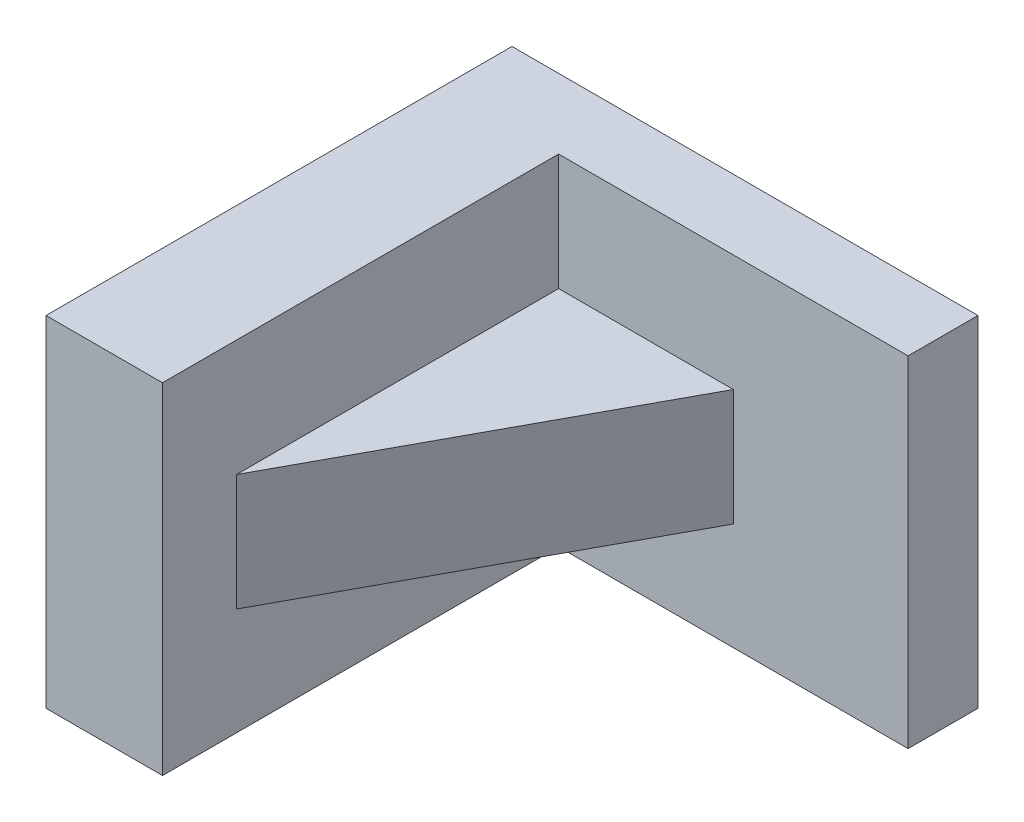
from build123d import *

# Parameters (mm, degrees)
BOSS_EXTRUDE1_DEPTH = 37.084
BOSS_EXTRUDE2_DEPTH = 6.35


with BuildPart() as part:
    # Sketch1 → Boss-Extrude1 (new body)
    with BuildSketch(Plane(origin=(0, 0, 0), x_dir=(1, 0, 0), z_dir=(0, 1, 0))):
        Polygon((14.31530778, 27.743714137), (-36.48469222, 27.743714137), (-36.48469222, -23.056285863), (-23.78469222, -23.056285863), (-23.78469222, 20.123714137), (14.31530778, 20.123714137), align=None)
    extrude(amount=BOSS_EXTRUDE1_DEPTH)

    # Sketch4 → Boss-Extrude2 (add, symmetric)
    with BuildSketch(Plane(origin=(0, 18.034, 0), x_dir=(1, 0, 0), z_dir=(0, 1, 0))):
        Polygon((-23.78469222, -14.982003078), (-4.73469222, 20.123714137), (-23.78469222, 20.123714137), align=None)
    extrude(amount=BOSS_EXTRUDE2_DEPTH, both=True)


solid = part.part
